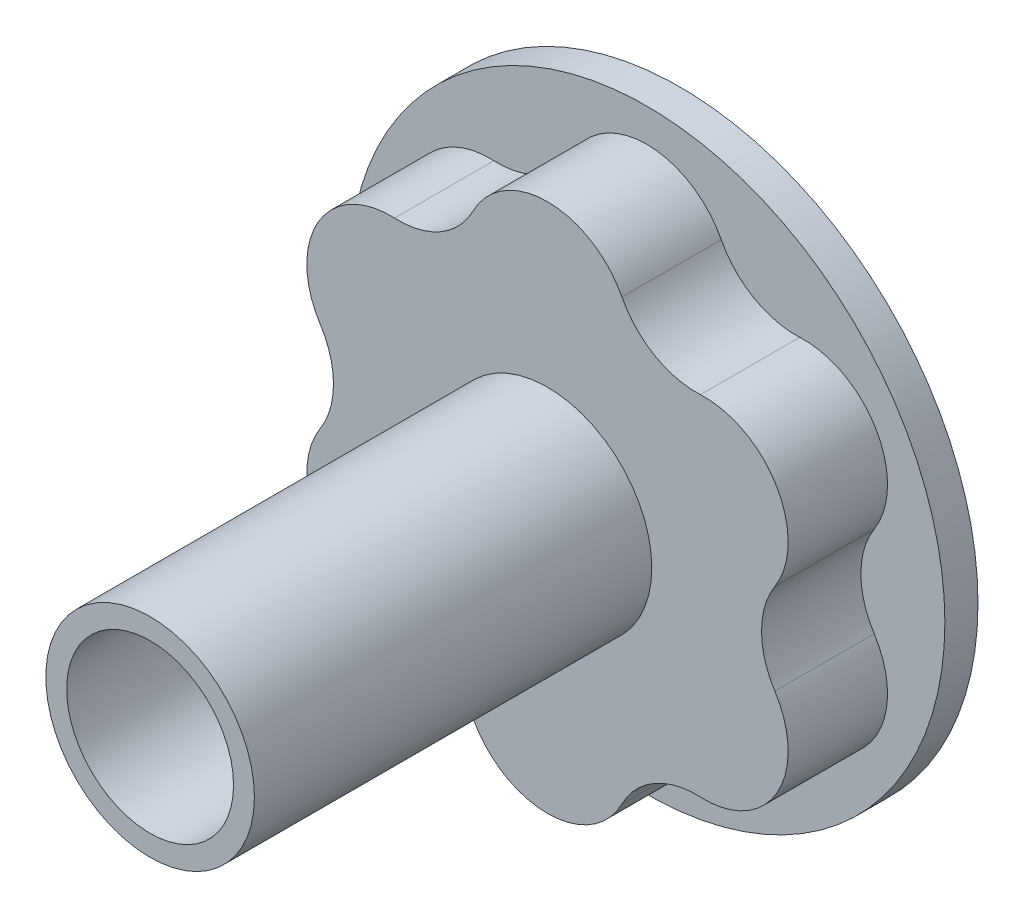
from build123d import *

# Parameters (mm, degrees)
SKETCH1_R           = 3
BOSS_EXTRUDE1_DEPTH = 4.7625
SKETCH2_R           = 14.2875
SKETCH2_R_2         = 3
BOSS_EXTRUDE2_DEPTH = 1.5875
SKETCH3_R           = 5
SKETCH3_R_2         = 3
BOSS_EXTRUDE3_DEPTH = 19.05
SKETCH4_R           = 4
CUT_EXTRUDE1_DEPTH  = 9.525


with BuildPart() as part:
    # Sketch1 → Boss-Extrude1 (new body)
    with BuildSketch(Plane.XY):
        with BuildLine():
            ThreePointArc((-3.568592622, 10.523915761), (0, 12.7), (3.568592622, 10.523915761))
            ThreePointArc((3.568592622, 10.523915761), (5.130117272, 8.885623765), (7.329682086, 8.352449747))
            ThreePointArc((7.329682086, 8.352449747), (10.998522628, 6.35), (10.898274707, 2.171466014))
            ThreePointArc((10.898274707, 2.171466014), (10.260234545, 0), (10.898274707, -2.171466014))
            ThreePointArc((10.898274707, -2.171466014), (10.998522628, -6.35), (7.329682086, -8.352449747))
            ThreePointArc((7.329682086, -8.352449747), (5.130117272, -8.885623765), (3.568592622, -10.523915761))
            ThreePointArc((3.568592622, -10.523915761), (0, -12.7), (-3.568592622, -10.523915761))
            ThreePointArc((-3.568592622, -10.523915761), (-5.130117272, -8.885623765), (-7.329682086, -8.352449747))
            ThreePointArc((-7.329682086, -8.352449747), (-10.998522628, -6.35), (-10.898274707, -2.171466014))
            ThreePointArc((-10.898274707, -2.171466014), (-10.260234545, 0), (-10.898274707, 2.171466014))
            ThreePointArc((-10.898274707, 2.171466014), (-10.998522628, 6.35), (-7.329682086, 8.352449747))
            ThreePointArc((-7.329682086, 8.352449747), (-5.130117272, 8.885623765), (-3.568592622, 10.523915761))
        make_face()
        Circle(SKETCH1_R, mode=Mode.SUBTRACT)
    extrude(amount=BOSS_EXTRUDE1_DEPTH)

    # Sketch2 → Boss-Extrude2 (add)
    with BuildSketch(Plane(origin=(0, 0, 0), x_dir=(-1, 0, 0), z_dir=(0, 0, -1))):
        Circle(SKETCH2_R)
        Circle(SKETCH2_R_2, mode=Mode.SUBTRACT)
    extrude(amount=BOSS_EXTRUDE2_DEPTH)

    # Sketch3 → Boss-Extrude3 (add)
    with BuildSketch(Plane.XY.offset(4.7625)):
        Circle(SKETCH3_R)
        Circle(SKETCH3_R_2, mode=Mode.SUBTRACT)
    extrude(amount=BOSS_EXTRUDE3_DEPTH)

    # Sketch4 → Cut-Extrude1 (cut)
    with BuildSketch(Plane.XY.offset(23.8125)):
        Circle(SKETCH4_R)
    extrude(amount=-CUT_EXTRUDE1_DEPTH, mode=Mode.SUBTRACT)


solid = part.part
